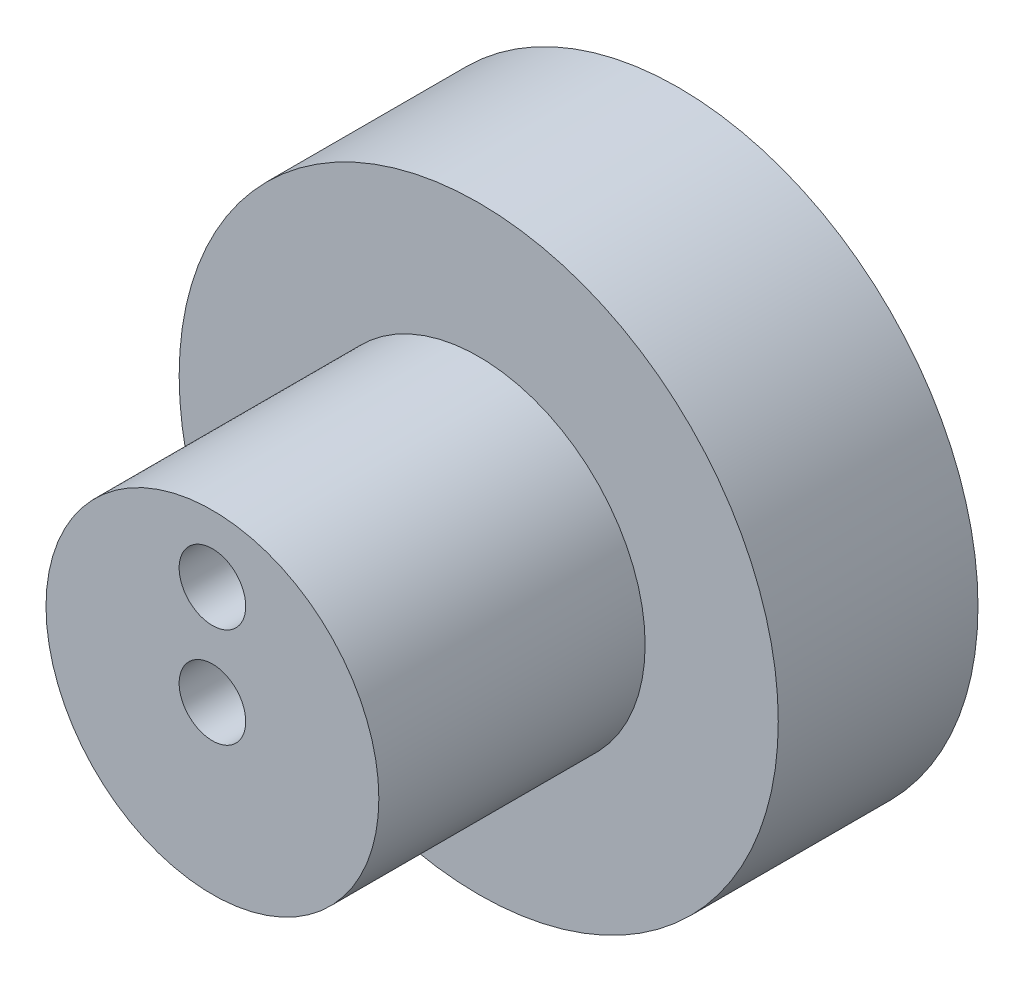
from build123d import *

# Parameters (mm, degrees)
ESQUISSE1_R             = 45
BOSS_EXTRU_1_DEPTH      = 30
ESQUISSE2_R             = 25
BOSS_EXTRU_2_DEPTH      = 40
ESQUISSE3_R             = 5
ENL_V_MAT_EXTRU_1_DEPTH = 71
ESQUISSE6_R             = 5
ENL_V_MAT_EXTRU_3_DEPTH = 10
ESQUISSE7_R             = 5
ENL_V_MAT_EXTRU_4_DEPTH = 10


with BuildPart() as part:
    # Esquisse1 → Boss.-Extru.1 (new body)
    with BuildSketch(Plane.XY):
        Circle(ESQUISSE1_R)
    extrude(amount=BOSS_EXTRU_1_DEPTH)

    # Esquisse2 → Boss.-Extru.2 (add)
    with BuildSketch(Plane.XY.offset(30)):
        Circle(ESQUISSE2_R)
    extrude(amount=BOSS_EXTRU_2_DEPTH)

    # Esquisse3 → Enlèv. mat.-Extru.1 (cut, through all)
    with BuildSketch(Plane.XY.offset(70)):
        Circle(ESQUISSE3_R)
    extrude(amount=-ENL_V_MAT_EXTRU_1_DEPTH, mode=Mode.SUBTRACT)

    # Esquisse6 → Enlèv. mat.-Extru.3 (cut)
    with BuildSketch(Plane.XY.offset(70)):
        with Locations((0, 15)):
            Circle(ESQUISSE6_R)
    extrude(amount=-ENL_V_MAT_EXTRU_3_DEPTH, mode=Mode.SUBTRACT)

    # Esquisse7 → Enlèv. mat.-Extru.4 (cut)
    with BuildSketch(Plane(origin=(0, 0, 0), x_dir=(-1, 0, 0), z_dir=(0, 0, -1))):
        with Locations((0, 15)):
            Circle(ESQUISSE7_R)
    extrude(amount=-ENL_V_MAT_EXTRU_4_DEPTH, mode=Mode.SUBTRACT)


solid = part.part
